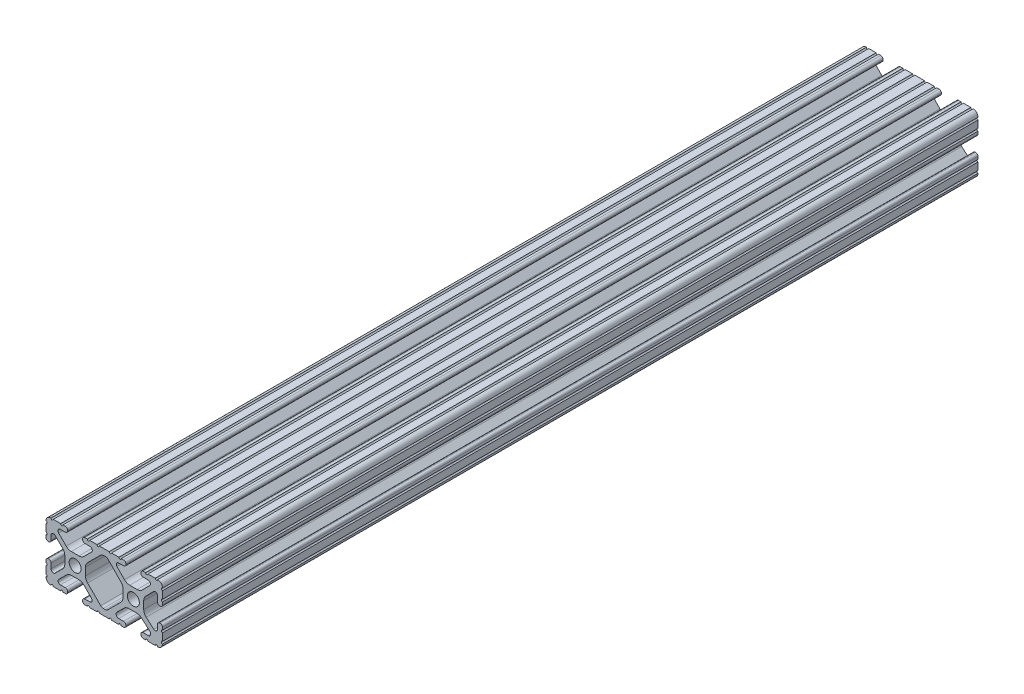
from build123d import *

# Parameters (mm, degrees)
SKETCH1_R           = 2.6035
BOSS_EXTRUDE1_DEPTH = 177.8


with BuildPart() as part:
    # Sketch1 → Boss-Extrude1 (new body, symmetric)
    with BuildSketch(Plane.XY):
        with BuildLine():
            Line((18.01710265, 12.7), (16.98745015, 12.7))
            ThreePointArc((16.98745015, 12.7), (16.245730386, 12.392769614), (15.9385, 11.65104985))
            Line((15.9385, 11.65104985), (15.9385, 11.53922))
            ThreePointArc((15.9385, 11.53922), (16.245750844, 10.797450844), (16.98752, 10.4902))
            Line((16.98752, 10.4902), (19.116384363, 10.4902))
            ThreePointArc((19.116384363, 10.4902), (20.052502933, 9.869096983), (19.844087081, 8.765172272))
            Line((19.844087081, 8.765172272), (16.618993479, 5.455112286))
            ThreePointArc((16.618993479, 5.455112286), (15.578994274, 4.745442459), (14.344932584, 4.4958))
            Line((14.344932584, 4.4958), (11.083317835, 4.4958))
            ThreePointArc((11.083317835, 4.4958), (9.854330953, 4.743306833), (8.816955189, 5.447238587))
            Line((8.816955189, 5.447238587), (5.564154119, 8.762652677))
            ThreePointArc((5.564154119, 8.762652677), (5.352591412, 9.867473037), (6.289393385, 10.4902))
            Line((6.289393385, 10.4902), (8.41248, 10.4902))
            ThreePointArc((8.41248, 10.4902), (9.154249156, 10.797450844), (9.4615, 11.53922))
            Line((9.4615, 11.53922), (9.4615, 11.65104985))
            ThreePointArc((9.4615, 11.65104985), (9.154269614, 12.392769614), (8.41254985, 12.7))
            Line((8.41254985, 12.7), (7.38288465, 12.7))
            ThreePointArc((7.38288465, 12.7), (6.87488465, 12.192), (6.36688465, 12.7))
            Line((6.36688465, 12.7), (3.14958095, 12.7))
            ThreePointArc((3.14958095, 12.7), (2.64158095, 12.192), (2.13358095, 12.7))
            Line((2.13358095, 12.7), (-2.13358095, 12.7))
            ThreePointArc((-2.13358095, 12.7), (-2.64158095, 12.192), (-3.14958095, 12.7))
            Line((-3.14958095, 12.7), (-6.36689735, 12.7))
            ThreePointArc((-6.36689735, 12.7), (-6.87489735, 12.192), (-7.38289735, 12.7))
            Line((-7.38289735, 12.7), (-8.41254985, 12.7))
            ThreePointArc((-8.41254985, 12.7), (-9.154269614, 12.392769614), (-9.4615, 11.65104985))
            Line((-9.4615, 11.65104985), (-9.4615, 11.53922))
            ThreePointArc((-9.4615, 11.53922), (-9.154249156, 10.797450844), (-8.41248, 10.4902))
            Line((-8.41248, 10.4902), (-6.283641037, 10.4902))
            ThreePointArc((-6.283641037, 10.4902), (-5.297291557, 9.829633109), (-5.532576693, 8.666071843))
            Line((-5.532576693, 8.666071843), (-8.809985098, 5.416263103))
            ThreePointArc((-8.809985098, 5.416263103), (-9.836720513, 4.734920264), (-11.045536121, 4.4958))
            Line((-11.045536121, 4.4958), (-14.354463879, 4.4958))
            ThreePointArc((-14.354463879, 4.4958), (-15.563279487, 4.734920264), (-16.590014902, 5.416263103))
            Line((-16.590014902, 5.416263103), (-19.867423307, 8.666071843))
            ThreePointArc((-19.867423307, 8.666071843), (-20.102708443, 9.829633109), (-19.116358963, 10.4902))
            Line((-19.116358963, 10.4902), (-16.98752, 10.4902))
            ThreePointArc((-16.98752, 10.4902), (-16.245750844, 10.797450844), (-15.9385, 11.53922))
            Line((-15.9385, 11.53922), (-15.9385, 11.65104985))
            ThreePointArc((-15.9385, 11.65104985), (-16.245730386, 12.392769614), (-16.98745015, 12.7))
            Line((-16.98745015, 12.7), (-18.01711535, 12.7))
            ThreePointArc((-18.01711535, 12.7), (-18.52511535, 12.192), (-19.03311535, 12.7))
            Line((-19.03311535, 12.7), (-22.2504, 12.7))
            ThreePointArc((-22.2504, 12.7), (-22.758323491, 12.192000006), (-23.266399977, 12.699846982))
            ThreePointArc((-23.266399977, 12.699846982), (-24.782522516, 12.082522516), (-25.399846982, 10.566399977))
            ThreePointArc((-25.399846982, 10.566399977), (-24.892000006, 10.058323491), (-25.4, 9.5504))
            Line((-25.4, 9.5504), (-25.4, 6.3330836))
            ThreePointArc((-25.4, 6.3330836), (-24.892, 5.8250836), (-25.4, 5.3170836))
            Line((-25.4, 5.3170836), (-25.4, 4.237520184))
            ThreePointArc((-25.4, 4.237520184), (-25.107393763, 3.531106237), (-24.400979816, 3.2385))
            Line((-24.400979816, 3.2385), (-24.23922, 3.2385))
            ThreePointArc((-24.23922, 3.2385), (-23.497450844, 3.545750844), (-23.1902, 4.28752))
            Line((-23.1902, 4.28752), (-23.1902, 6.334741132))
            ThreePointArc((-23.1902, 6.334741132), (-22.556026952, 7.286023527), (-21.434002553, 7.066535717))
            Line((-21.434002553, 7.066535717), (-18.147950853, 3.808156468))
            ThreePointArc((-18.147950853, 3.808156468), (-17.452759693, 2.774838327), (-17.208501877, 1.553619571))
            Line((-17.208501877, 1.553619571), (-17.208501877, -1.695179196))
            ThreePointArc((-17.208501877, -1.695179196), (-17.450738657, -2.911536421), (-18.140486065, -3.942289578))
            Line((-18.140486065, -3.942289578), (-21.431579576, -7.227386226))
            ThreePointArc((-21.431579576, -7.227386226), (-22.55444896, -7.449940594), (-23.1902, -6.498002195))
            Line((-23.1902, -6.498002195), (-23.1902, -4.28752))
            ThreePointArc((-23.1902, -4.28752), (-23.497450844, -3.545750844), (-24.23922, -3.2385))
            Line((-24.23922, -3.2385), (-24.35098, -3.2385))
            ThreePointArc((-24.35098, -3.2385), (-25.092749156, -3.545750844), (-25.4, -4.28752))
            Line((-25.4, -4.28752), (-25.4, -5.3171344))
            ThreePointArc((-25.4, -5.3171344), (-24.892, -5.8251344), (-25.4, -6.3331344))
            Line((-25.4, -6.3331344), (-25.4, -9.5504))
            ThreePointArc((-25.4, -9.5504), (-24.892000006, -10.058323491), (-25.399846982, -10.566399977))
            ThreePointArc((-25.399846982, -10.566399977), (-24.782522516, -12.082522516), (-23.266399977, -12.699846982))
            ThreePointArc((-23.266399977, -12.699846982), (-22.758323491, -12.192000006), (-22.2504, -12.7))
            Line((-22.2504, -12.7), (-19.03308995, -12.7))
            ThreePointArc((-19.03308995, -12.7), (-18.52508995, -12.192), (-18.01708995, -12.7))
            Line((-18.01708995, -12.7), (-16.9874692, -12.7))
            ThreePointArc((-16.9874692, -12.7), (-16.245700044, -12.392749156), (-15.9384492, -11.65098))
            Line((-15.9384492, -11.65098), (-15.9384492, -11.53922))
            ThreePointArc((-15.9384492, -11.53922), (-16.245700044, -10.797450844), (-16.9874692, -10.4902))
            Line((-16.9874692, -10.4902), (-19.116358963, -10.4902))
            ThreePointArc((-19.116358963, -10.4902), (-20.055197748, -9.862578342), (-19.834124023, -8.755124678))
            Line((-19.834124023, -8.755124678), (-16.49660751, -5.423689618))
            ThreePointArc((-16.49660751, -5.423689618), (-15.467274017, -4.736928798), (-14.253591699, -4.4958))
            Line((-14.253591699, -4.4958), (-11.146408301, -4.4958))
            ThreePointArc((-11.146408301, -4.4958), (-9.932725983, -4.736928798), (-8.90339249, -5.423689618))
            Line((-8.90339249, -5.423689618), (-5.565875977, -8.755124678))
            ThreePointArc((-5.565875977, -8.755124678), (-5.344802252, -9.862578342), (-6.283641037, -10.4902))
            Line((-6.283641037, -10.4902), (-8.4125308, -10.4902))
            ThreePointArc((-8.4125308, -10.4902), (-9.154299956, -10.797450844), (-9.4615508, -11.53922))
            Line((-9.4615508, -11.53922), (-9.4615508, -11.65098))
            ThreePointArc((-9.4615508, -11.65098), (-9.154299956, -12.392749156), (-8.4125308, -12.7))
            Line((-8.4125308, -12.7), (-7.38287195, -12.7))
            ThreePointArc((-7.38287195, -12.7), (-6.87487195, -12.192), (-6.36687195, -12.7))
            Line((-6.36687195, -12.7), (-3.14960635, -12.7))
            ThreePointArc((-3.14960635, -12.7), (-2.64160635, -12.192), (-2.13360635, -12.7))
            Line((-2.13360635, -12.7), (2.13360635, -12.7))
            ThreePointArc((2.13360635, -12.7), (2.64159365, -12.1920127), (3.14958095, -12.7))
            Line((3.14958095, -12.7), (6.36691005, -12.7))
            ThreePointArc((6.36691005, -12.7), (6.87491005, -12.192), (7.38291005, -12.7))
            Line((7.38291005, -12.7), (8.4125308, -12.7))
            ThreePointArc((8.4125308, -12.7), (9.154299956, -12.392749156), (9.4615508, -11.65098))
            Line((9.4615508, -11.65098), (9.4615508, -11.53922))
            ThreePointArc((9.4615508, -11.53922), (9.154299956, -10.797450844), (8.4125308, -10.4902))
            Line((8.4125308, -10.4902), (6.289393385, -10.4902))
            ThreePointArc((6.289393385, -10.4902), (5.231590322, -9.783049717), (5.480677245, -8.535265862))
            Line((5.480677245, -8.535265862), (8.597933595, -5.423689618))
            ThreePointArc((8.597933595, -5.423689618), (9.627267088, -4.736928798), (10.840949406, -4.4958))
            Line((10.840949406, -4.4958), (14.102564155, -4.4958))
            ThreePointArc((14.102564155, -4.4958), (15.215927525, -4.697410182), (16.187895372, -5.276636531))
            Line((16.187895372, -5.276636531), (19.868247549, -8.482246082))
            ThreePointArc((19.868247549, -8.482246082), (20.188435806, -9.746879864), (19.116384363, -10.4902))
            Line((19.116384363, -10.4902), (16.9874692, -10.4902))
            ThreePointArc((16.9874692, -10.4902), (16.245700044, -10.797450844), (15.9384492, -11.53922))
            Line((15.9384492, -11.53922), (15.9384492, -11.65098))
            ThreePointArc((15.9384492, -11.65098), (16.245700044, -12.392749156), (16.9874692, -12.7))
            Line((16.9874692, -12.7), (18.01710265, -12.7))
            ThreePointArc((18.01710265, -12.7), (18.52510265, -12.192), (19.03310265, -12.7))
            Line((19.03310265, -12.7), (22.2504, -12.7))
            ThreePointArc((22.2504, -12.7), (22.758323491, -12.192000006), (23.266399977, -12.699846982))
            ThreePointArc((23.266399977, -12.699846982), (24.782522516, -12.082522516), (25.399846982, -10.566399977))
            ThreePointArc((25.399846982, -10.566399977), (24.892000006, -10.058323492), (25.4, -9.550400001))
            Line((25.4, -9.550400001), (25.4, -6.333083592))
            ThreePointArc((25.4, -6.333083592), (24.892000001, -5.825083593), (25.4, -5.317083593))
            Line((25.4, -5.317083593), (25.4, -4.237520184))
            ThreePointArc((25.4, -4.237520184), (25.107393763, -3.531106237), (24.400979816, -3.2385))
            Line((24.400979816, -3.2385), (24.189220184, -3.2385))
            ThreePointArc((24.189220184, -3.2385), (23.482806237, -3.531106237), (23.1902, -4.237520184))
            Line((23.1902, -4.237520184), (23.1902, -6.155876159))
            ThreePointArc((23.1902, -6.155876159), (22.62232736, -7.038258539), (21.583974541, -6.886926384))
            Line((21.583974541, -6.886926384), (18.29817066, -4.024970844))
            ThreePointArc((18.29817066, -4.024970844), (17.493730985, -2.946044689), (17.208501877, -1.630807374))
            Line((17.208501877, -1.630807374), (17.208501877, 1.630807374))
            ThreePointArc((17.208501877, 1.630807374), (17.442348332, 2.82673414), (18.109440981, 3.846495088))
            Line((18.109440981, 3.846495088), (21.526346532, 7.353420386))
            ThreePointArc((21.526346532, 7.353420386), (22.585896263, 7.574939077), (23.1902, 6.676867167))
            Line((23.1902, 6.676867167), (23.1902, 4.237520184))
            ThreePointArc((23.1902, 4.237520184), (23.482806237, 3.531106237), (24.189220184, 3.2385))
            Line((24.189220184, 3.2385), (24.400979816, 3.2385))
            ThreePointArc((24.400979816, 3.2385), (25.107393763, 3.531106237), (25.4, 4.237520184))
            Line((25.4, 4.237520184), (25.4, 5.3170836))
            ThreePointArc((25.4, 5.3170836), (24.891949193, 5.825134407), (25.4, 6.333185215))
            Line((25.4, 6.333185215), (25.4, 9.550400015))
            ThreePointArc((25.4, 9.550400015), (24.892000013, 10.058323498), (25.399846982, 10.566399977))
            ThreePointArc((25.399846982, 10.566399977), (24.782522516, 12.082522516), (23.266399977, 12.699846982))
            ThreePointArc((23.266399977, 12.699846982), (22.758323491, 12.192000006), (22.2504, 12.7))
            Line((22.2504, 12.7), (19.03310265, 12.7))
            ThreePointArc((19.03310265, 12.7), (18.52510265, 12.192), (18.01710265, 12.7))
        make_face()
        with Locations((-12.7, 0)):
            Circle(SKETCH1_R, mode=Mode.SUBTRACT)
        with Locations((12.7, 0)):
            Circle(SKETCH1_R, mode=Mode.SUBTRACT)
        with BuildLine():
            Line((-7.259513935, -3.869413038), (-1.545748891, -9.572766749))
            ThreePointArc((-1.545748891, -9.572766749), (-1.035199478, -9.913400116), (-0.433213048, -10.033))
            Line((-0.433213048, -10.033), (0.433213048, -10.033))
            ThreePointArc((0.433213048, -10.033), (1.035199478, -9.913400116), (1.545748891, -9.572766749))
            Line((1.545748891, -9.572766749), (7.259513935, -3.869413038))
            ThreePointArc((7.259513935, -3.869413038), (7.949261343, -2.838659881), (8.191498123, -1.622302656))
            Line((8.191498123, -1.622302656), (8.191498123, 1.622302656))
            ThreePointArc((8.191498123, 1.622302656), (7.955573352, 2.823327967), (7.282860769, 3.845864069))
            Line((7.282860769, 3.845864069), (1.675572808, 9.561086461))
            ThreePointArc((1.675572808, 9.561086461), (1.161034429, 9.910236611), (0.551456936, 10.033))
            Line((0.551456936, 10.033), (-0.395199982, 10.033))
            ThreePointArc((-0.395199982, 10.033), (-0.994772524, 9.914396349), (-1.50403329, 9.576450301))
            Line((-1.50403329, 9.576450301), (-7.252049147, 3.876839553))
            ThreePointArc((-7.252049147, 3.876839553), (-7.947240307, 2.843521412), (-8.191498123, 1.622302656))
            Line((-8.191498123, 1.622302656), (-8.191498123, -1.622302656))
            ThreePointArc((-8.191498123, -1.622302656), (-7.949261343, -2.838659881), (-7.259513935, -3.869413038))
        make_face(mode=Mode.SUBTRACT)
    extrude(amount=BOSS_EXTRUDE1_DEPTH, both=True)


solid = part.part
